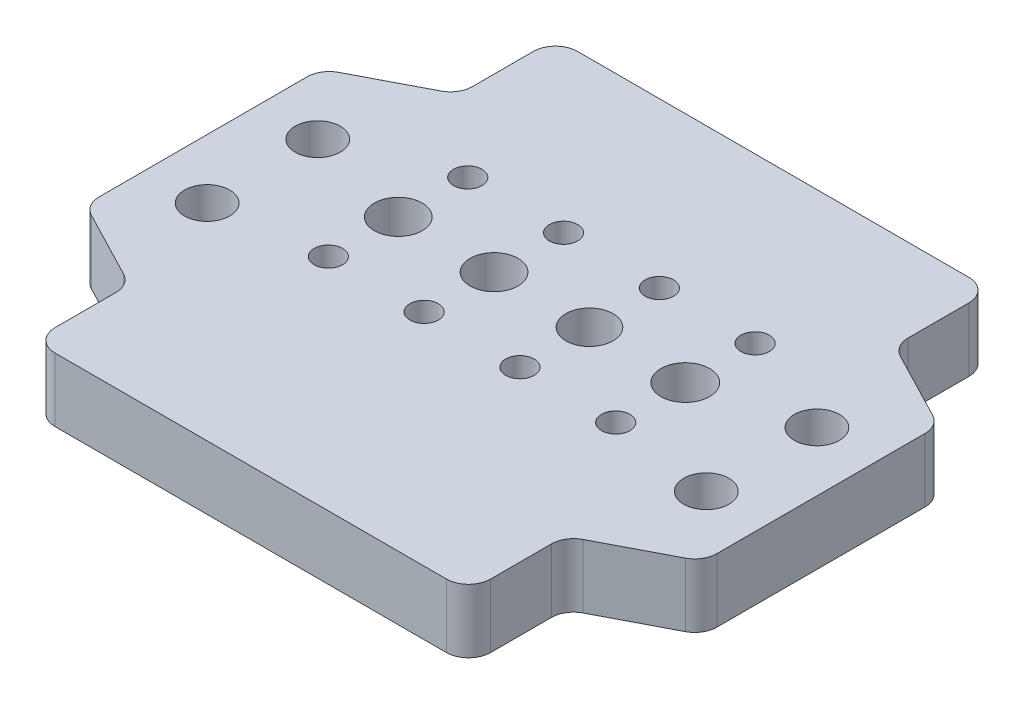
from build123d import *

# Parameters (mm, degrees)
SKETCH1_W                                         = 70.945719932
SKETCH1_H                                         = 60
BOSS_EXTRUDE1_DEPTH                               = 7.3152
F_6_0_204_DIAMETER_HOLE1_D                        = 5.1816
FILLET1_R                                         = 2.54
CUT_EXTRUDE1_DEPTH                                = 8.3152
FILLET2_R                                         = 2.54
MIRROR4_AT_THE_SECOND_PLANE_COPY_1_DEPTH          = 8.3152
FILLET3_R                                         = 2.54
CSK_FOR_4_FLAT_HEAD_SOCKET_CAP_SCREW1_D           = 3.2639
CSK_FOR_4_FLAT_HEAD_SOCKET_CAP_SCREW1_CSINK_D     = 6.477
CSK_FOR_4_FLAT_HEAD_SOCKET_CAP_SCREW1_CSINK_ANGLE = 82
SKETCH9_R                                         = 2.75286662
SKETCH9_R_2                                       = 2.796567759
SKETCH9_R_3                                       = 2.709165481
CUT_EXTRUDE2_DEPTH                                = 8.3152


with BuildPart() as part:
    # Sketch1 → Boss-Extrude1 (new body)
    with BuildSketch(Plane(origin=(0, 0, 0), x_dir=(1, 0, 0), z_dir=(0, 1, 0))):
        Rectangle(SKETCH1_W, SKETCH1_H)
    extrude(amount=BOSS_EXTRUDE1_DEPTH)

    # 6 _0.204_ Diameter Hole1 (through all)
    with Locations(Plane(origin=(-28.662459966, 7.3152, 6.3474), x_dir=(0, 0, 1), z_dir=(0, 1, 0))):
        with Locations((0, 0), (-12.7, 0)):
            f_6_0_204_diameter_hole1 = Hole(F_6_0_204_DIAMETER_HOLE1_D / 2)

    # Mirror2: 6 _0.204_ Diameter Hole1 across plane
    add(f_6_0_204_diameter_hole1.mirror(Plane(origin=(0, 0, 0), x_dir=(0, 0, 1), z_dir=(1, 0, 0))), mode=Mode.SUBTRACT)

    # Fillet1
    fillet1_edges = [part.edges().sort_by_distance(p)[0] for p in [
        (-35.472859966, 3.6576, -30),
        (35.472859966, 3.6576, -30),
        (35.472859966, 3.6576, 30),
        (-35.472859966, 3.6576, 30),
    ]]
    fillet(fillet1_edges, radius=FILLET1_R)

    # Sketch4 → Cut-Extrude1 (cut, through all)
    with BuildSketch(Plane(origin=(0, 7.3152, 0), x_dir=(1, 0, 0), z_dir=(0, 1, 0))):
        Polygon((-35.472859966, 13.49), (-25.007259027, 18.930947869), (-25.007259027, 30), (-35.472859966, 30), align=None)
    cut_extrude1 = extrude(amount=-CUT_EXTRUDE1_DEPTH, mode=Mode.SUBTRACT)

    # Fillet2
    fillet2_edges = [part.edges().sort_by_distance(p)[0] for p in [
        (-35.472859966, 3.6576, -13.49),
        (-25.007259027, 3.6576, -30),
        (-25.007259027, 3.6576, -18.930947869),
    ]]
    fillet(fillet2_edges, radius=FILLET2_R)

    # Mirror4: Cut-Extrude1 across plane
    add(cut_extrude1.mirror(Plane(origin=(0, 0, 0), x_dir=(0, 0, 1), z_dir=(1, 0, 0))), mode=Mode.SUBTRACT)

    # Mirror4 at the second plane: Cut-Extrude1 across plane
    add(cut_extrude1.mirror(Plane.XY), mode=Mode.SUBTRACT)

    # Mirror4 at the second plane copy 1 sketc → Mirror4 at the second plane copy 1 (cut, through all)
    with BuildSketch(Plane(origin=(0, 7.3152, 0), x_dir=(-1, 0, 0), z_dir=(0, 1, 0))):
        Polygon((-35.472859966, 13.49), (-25.007259027, 18.930947869), (-25.007259027, 30), (-35.472859966, 30), align=None)
    extrude(amount=-MIRROR4_AT_THE_SECOND_PLANE_COPY_1_DEPTH, mode=Mode.SUBTRACT)

    # Fillet3
    fillet3_edges = [part.edges().sort_by_distance(p)[0] for p in [
        (-25.007259027, 3.6576, 30),
        (-35.472859966, 3.6576, 13.49),
        (-25.007259027, 3.6576, 18.930947869),
        (25.007259027, 3.6576, -30),
        (35.472859966, 3.6576, -13.49),
        (25.007259027, 3.6576, -18.930947869),
        (35.472859966, 3.6576, 13.49),
        (25.007259027, 3.6576, 30),
        (25.007259027, 3.6576, 18.930947869),
    ]]
    fillet(fillet3_edges, radius=FILLET3_R)

    # CSK for _4 Flat Head Socket Cap Screw1 (through all)
    with Locations(Plane(origin=(0, 0, 0), x_dir=(-1, 0, 0), z_dir=(0, -1, 0))):
        with Locations((-16.755284659, 11.161371127), (-5.755284659, 11.161371127), (5.244715341, 11.161371127), (16.244715341, 11.161371127), (16.377640294, -4.713072358), (5.377640294, -4.713072358), (-5.622359706, -4.713072358), (-16.622359706, -4.713072358)):
            CounterSinkHole(CSK_FOR_4_FLAT_HEAD_SOCKET_CAP_SCREW1_D / 2, CSK_FOR_4_FLAT_HEAD_SOCKET_CAP_SCREW1_CSINK_D / 2, counter_sink_angle=CSK_FOR_4_FLAT_HEAD_SOCKET_CAP_SCREW1_CSINK_ANGLE)

    # Sketch9 → Cut-Extrude2 (cut, through all)
    with BuildSketch(Plane(origin=(0, 7.3152, 0), x_dir=(1, 0, 0), z_dir=(0, 1, 0))):
        with Locations((-16.310955927, 3.250648456)):
            Circle(SKETCH9_R)
        with Locations((-5.310955927, 3.250648456)):
            Circle(SKETCH9_R)
        with Locations((16.645347782, 3.251299402)):
            Circle(SKETCH9_R_2)
        with Locations((5.645347782, 3.251299402)):
            Circle(SKETCH9_R_3)
    extrude(amount=-CUT_EXTRUDE2_DEPTH, mode=Mode.SUBTRACT)


solid = part.part
